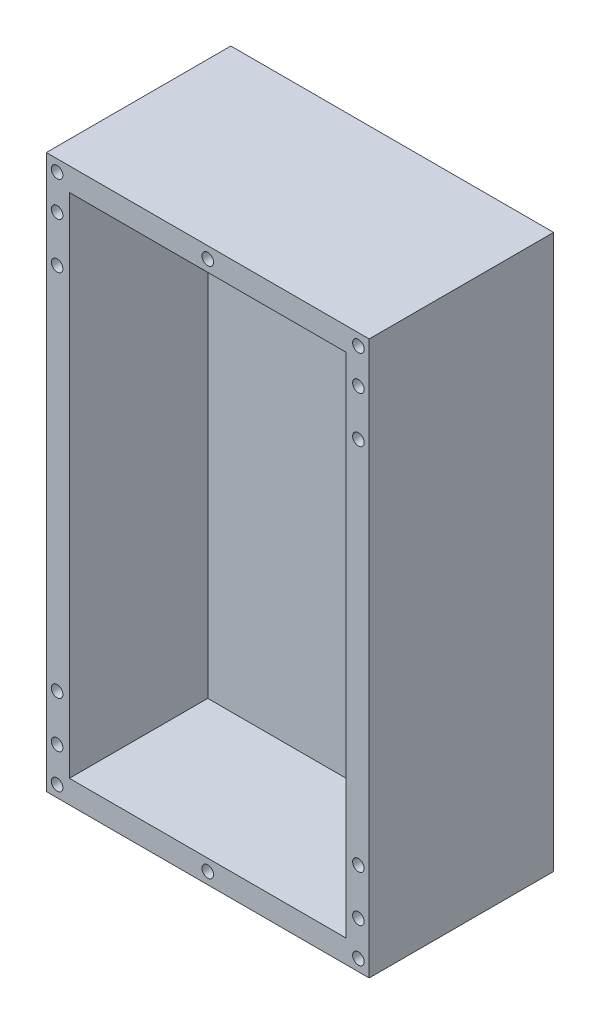
from build123d import *

# Parameters (mm, degrees)
SKETCH1_W           = 355.6
SKETCH1_H           = 609.6
SKETCH1_W_2         = 304.8
SKETCH1_H_2         = 558.8
BOSS_EXTRUDE2_DEPTH = 203.2
SKETCH4_W           = 304.8
SKETCH4_H           = 558.8
BOSS_EXTRUDE3_DEPTH = 50.8
SKETCH5_R           = 6.35
CUT_EXTRUDE1_DEPTH  = 25.4
SKETCH6_R           = 6.35
CUT_EXTRUDE2_DEPTH  = 12.7


with BuildPart() as part:
    # Sketch1 → Boss-Extrude2 (new body)
    with BuildSketch(Plane.XY):
        with Locations((177.8, 304.8)):
            Rectangle(SKETCH1_W, SKETCH1_H)
        with Locations((177.8, 304.8)):
            Rectangle(SKETCH1_W_2, SKETCH1_H_2, mode=Mode.SUBTRACT)
    extrude(amount=BOSS_EXTRUDE2_DEPTH)

    # Sketch4 → Boss-Extrude3 (add)
    with BuildSketch(Plane(origin=(0, 0, 0), x_dir=(-1, 0, 0), z_dir=(0, 0, -1))):
        with Locations((-177.8, 304.8)):
            Rectangle(SKETCH4_W, SKETCH4_H)
    extrude(amount=-BOSS_EXTRUDE3_DEPTH)

    # Sketch5 → Cut-Extrude1 (cut)
    with BuildSketch(Plane.XY.offset(203.2)):
        with Locations((11.88567414, 50.947353246)):
            Circle(SKETCH5_R)
        with Locations((11.88567414, 101.747353246)):
            Circle(SKETCH5_R)
        with Locations((11.88567414, 507.852646754)):
            Circle(SKETCH5_R)
        with Locations((11.88567414, 558.652646754)):
            Circle(SKETCH5_R)
        with Locations((343.71432586, 50.947353246)):
            Circle(SKETCH5_R)
        with Locations((343.71432586, 101.747353246)):
            Circle(SKETCH5_R)
        with Locations((343.71432586, 558.652646754)):
            Circle(SKETCH5_R)
        with Locations((343.71432586, 507.852646754)):
            Circle(SKETCH5_R)
    extrude(amount=-CUT_EXTRUDE1_DEPTH, mode=Mode.SUBTRACT)

    # Sketch6 → Cut-Extrude2 (cut)
    with BuildSketch(Plane.XY.offset(203.2)):
        with Locations((343.71432586, 596.9)):
            Circle(SKETCH6_R)
        with Locations((177.8, 596.9)):
            Circle(SKETCH6_R)
        with Locations((11.88567414, 596.9)):
            Circle(SKETCH6_R)
        with Locations((343.71432586, 12.7)):
            Circle(SKETCH6_R)
        with Locations((177.8, 12.7)):
            Circle(SKETCH6_R)
        with Locations((11.88567414, 12.7)):
            Circle(SKETCH6_R)
    extrude(amount=-CUT_EXTRUDE2_DEPTH, mode=Mode.SUBTRACT)


solid = part.part
